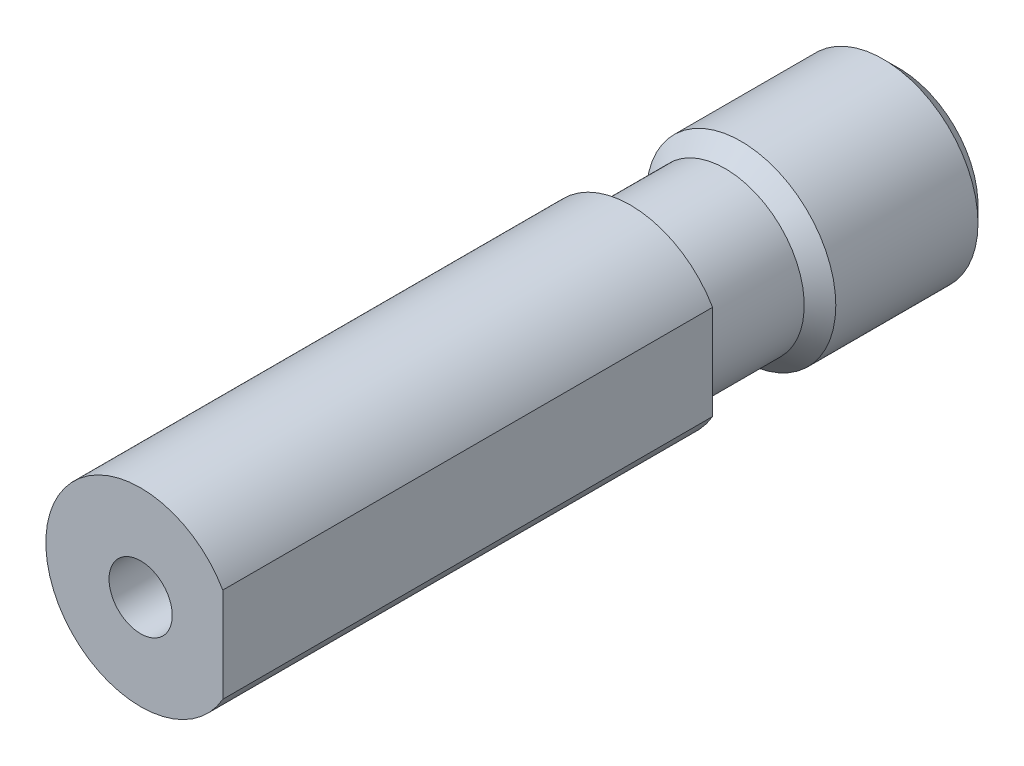
from build123d import *

# Parameters (mm, degrees)
BOSS_EXTRUDE1_DEPTH                                 = 15.5
CBORE_FOR_1_BINDING_HEAD_MACHINE_SCREW1_D           = 2
CBORE_FOR_1_BINDING_HEAD_MACHINE_SCREW1_DEPTH       = 24
CBORE_FOR_1_BINDING_HEAD_MACHINE_SCREW1_CBORE_D     = 4
CBORE_FOR_1_BINDING_HEAD_MACHINE_SCREW1_CBORE_DEPTH = 22
CHAMFER1_SIZE                                       = 0.5


with BuildPart() as part:
    # Sketch1 → Boss-Extrude1 (new body)
    with BuildSketch(Plane(origin=(0, 0, 8.5), x_dir=(-1, 0, 0), z_dir=(0, 0, -1))):
        with BuildLine():
            Line((-2.6, 1.496662955), (-2.6, -1.496662955))
            ThreePointArc((-2.6, -1.496662955), (3, 0), (-2.6, 1.496662955))
        make_face()
    extrude(amount=-BOSS_EXTRUDE1_DEPTH)

    # Sketch2 → Revolve1 (revolve)
    with BuildSketch(Plane.XZ):
        Polygon((2.5, 8.5), (0, 8.5), (0, 0), (3, 0), (3, 5), (2.5, 5.5), align=None)
    revolve(axis=Axis((0, 0, 8.5), (0, 0, -1)))

    # CBORE for #1 Binding Head Machine Screw1
    with Locations(Plane(origin=(0, 0, 0), x_dir=(-1, 0, 0), z_dir=(0, 0, -1))):
        with Locations((0, 0)):
            CounterBoreHole(CBORE_FOR_1_BINDING_HEAD_MACHINE_SCREW1_D / 2, CBORE_FOR_1_BINDING_HEAD_MACHINE_SCREW1_CBORE_D / 2, CBORE_FOR_1_BINDING_HEAD_MACHINE_SCREW1_CBORE_DEPTH, depth=CBORE_FOR_1_BINDING_HEAD_MACHINE_SCREW1_DEPTH)

    # Chamfer1
    chamfer1_edges = [part.edges().sort_by_distance(p)[0] for p in [
        (-3, 0, 0),
    ]]
    chamfer(chamfer1_edges, length=CHAMFER1_SIZE)


solid = part.part
